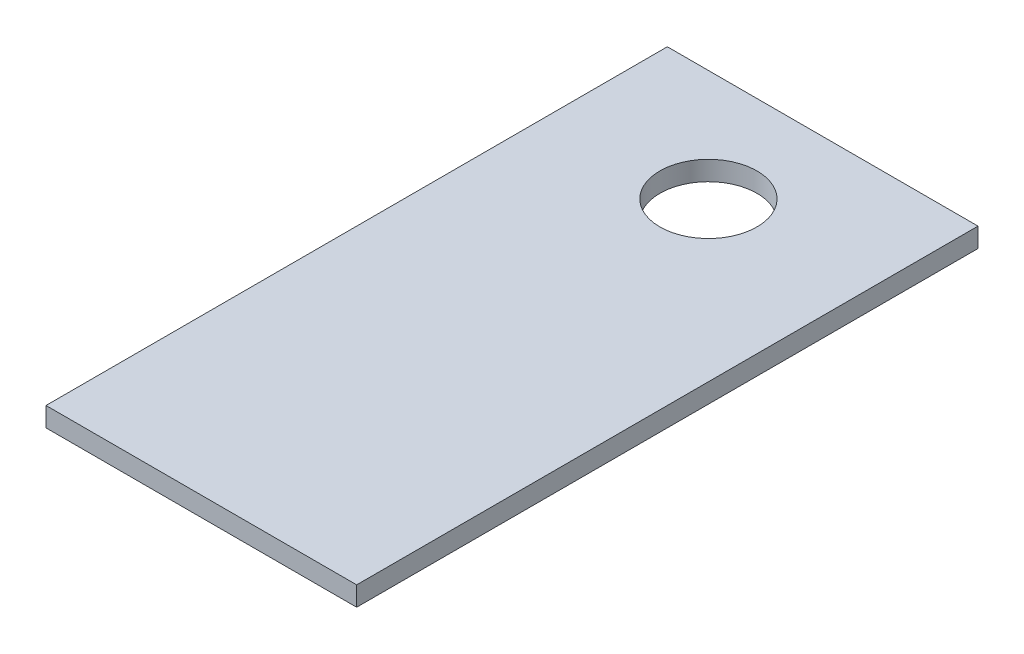
from build123d import *

# Parameters (mm, degrees)
SKETCH1_W           = 25.4
SKETCH1_H           = 50.8
SKETCH1_R           = 3.96875
BOSS_EXTRUDE1_DEPTH = 1.5875


with BuildPart() as part:
    # Sketch1 → Boss-Extrude1 (new body)
    with BuildSketch(Plane(origin=(0, 0, 0), x_dir=(1, 0, 0), z_dir=(0, 1, 0))):
        with Locations((12.7, 25.4)):
            Rectangle(SKETCH1_W, SKETCH1_H)
        with Locations((12.454193548, 41.70516129)):
            Circle(SKETCH1_R, mode=Mode.SUBTRACT)
    extrude(amount=BOSS_EXTRUDE1_DEPTH)


solid = part.part
